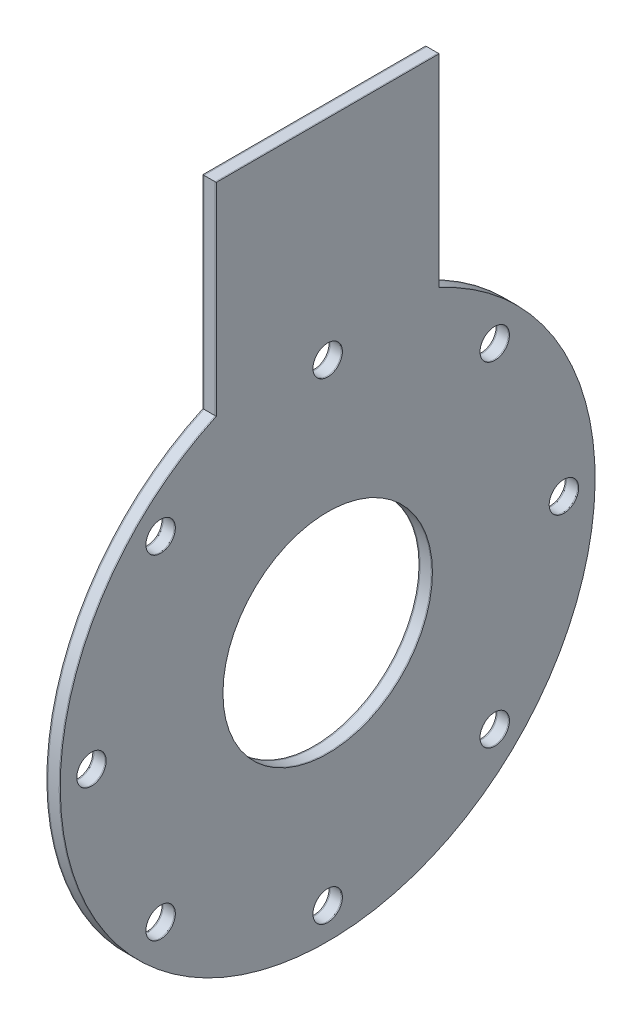
from build123d import *

# Parameters (mm, degrees)
SKETCH1_R                     = 60
SKETCH1_R_2                   = 23.5
BOSS_EXTRUDE1_DEPTH           = 0.25
SKETCH4_R                     = 23.5
BOSS_EXTRUDE4_DEPTH           = 2.5
SKETCH5_R                     = 23.5
BOSS_EXTRUDE5_DEPTH           = 0.25
SKETCH10_W                    = 3.3
SKETCH10_H                    = 3
M6_CLEARANCE_HOLE1_AT_2_COUNT = 2
M6_CLEARANCE_HOLE1_AT_2_PITCH = 40.564443831
M6_CLEARANCE_HOLE1_AT_3_COUNT = 2
M6_CLEARANCE_HOLE1_AT_3_PITCH = 74.953318806
M6_CLEARANCE_HOLE1_AT_4_COUNT = 2
M6_CLEARANCE_HOLE1_AT_4_PITCH = 97.931230446
M6_CLEARANCE_HOLE1_AT_5_COUNT = 2
M6_CLEARANCE_HOLE1_AT_5_PITCH = 106
M6_CLEARANCE_HOLE1_AT_6_COUNT = 2
M6_CLEARANCE_HOLE1_AT_6_PITCH = 97.931230446
M6_CLEARANCE_HOLE1_AT_7_COUNT = 2
M6_CLEARANCE_HOLE1_AT_7_PITCH = 74.953318806
M6_CLEARANCE_HOLE1_AT_8_COUNT = 2
M6_CLEARANCE_HOLE1_AT_8_PITCH = 40.564443831


with BuildPart() as part:
    # Sketch1 → Boss-Extrude1 (new body)
    with BuildSketch(Plane(origin=(0, 0, 0), x_dir=(0, 0, -1), z_dir=(1, 0, 0))):
        with BuildLine():
            Line((25, 100), (-25, 100))
            Line((-25, 100), (-25, 54.543560573))
            ThreePointArc((-25, 54.543560573), (0, 60), (25, 54.543560573))
            Line((25, 54.543560573), (25, 100))
        make_face()
        Circle(SKETCH1_R)
        Circle(SKETCH1_R_2, mode=Mode.SUBTRACT)
    extrude(amount=BOSS_EXTRUDE1_DEPTH)


with BuildPart() as body_2:
    # Sketch4 → Boss-Extrude4 (new body)
    with BuildSketch(Plane.ZY):
        with BuildLine():
            Line((25, 54.543560573), (25, 100))
            Line((25, 100), (-25, 100))
            Line((-25, 100), (-25, 54.543560573))
            ThreePointArc((-25, 54.543560573), (0, -60), (25, 54.543560573))
        make_face()
        Circle(SKETCH4_R, mode=Mode.SUBTRACT)
    extrude(amount=BOSS_EXTRUDE4_DEPTH)


with BuildPart() as body_3:
    # Sketch5 → Boss-Extrude5 (new body)
    with BuildSketch(Plane.ZY.offset(2.5)):
        with BuildLine():
            Line((25, 54.543560573), (25, 100))
            Line((25, 100), (-25, 100))
            Line((-25, 100), (-25, 54.543560573))
            ThreePointArc((-25, 54.543560573), (0, -60), (25, 54.543560573))
        make_face()
        Circle(SKETCH5_R, mode=Mode.SUBTRACT)
    extrude(amount=BOSS_EXTRUDE5_DEPTH)


with BuildPart() as m6_clearance_hole1_tool:
    # Sketch10 → M6 Clearance Hole1 (revolve)
    with BuildSketch(Plane(origin=(0.25, 37.476659403, -37.476659403), x_dir=(0, 0, -1), z_dir=(0, 1, 0))):
        with Locations((1.65, 1.5)):
            Rectangle(SKETCH10_W, SKETCH10_H)
    m6_clearance_hole1 = revolve(axis=Axis((6.6, 37.476659403, -37.476659403), (-1, 0, 0)))


with BuildPart() as part_1:
    add(part.part)

    # M6 Clearance Hole1: cut by m6_clearance_hole1_tool
    add(m6_clearance_hole1_tool.part, mode=Mode.SUBTRACT)


with BuildPart() as body_2_1:
    add(body_2.part)

    # M6 Clearance Hole1: cut by m6_clearance_hole1_tool
    add(m6_clearance_hole1_tool.part, mode=Mode.SUBTRACT)


with BuildPart() as body_3_1:
    add(body_3.part)

    # M6 Clearance Hole1: cut by m6_clearance_hole1_tool
    add(m6_clearance_hole1_tool.part, mode=Mode.SUBTRACT)


with BuildPart() as m6_clearance_hole1_at_2_tool:
    # M6 Clearance Hole1 at 2: M6 Clearance Hole1 ×2
    with Locations(*[Vector(0, -0.923879533, -0.382683432) * (i * M6_CLEARANCE_HOLE1_AT_2_PITCH) for i in range(1, M6_CLEARANCE_HOLE1_AT_2_COUNT)]):
        add(m6_clearance_hole1)


with BuildPart() as part_2:
    add(part_1.part)

    # M6 Clearance Hole1 at 2: cut by m6_clearance_hole1_at_2_tool
    add(m6_clearance_hole1_at_2_tool.part, mode=Mode.SUBTRACT)


with BuildPart() as body_2_2:
    add(body_2_1.part)

    # M6 Clearance Hole1 at 2: cut by m6_clearance_hole1_at_2_tool
    add(m6_clearance_hole1_at_2_tool.part, mode=Mode.SUBTRACT)


with BuildPart() as body_3_2:
    add(body_3_1.part)

    # M6 Clearance Hole1 at 2: cut by m6_clearance_hole1_at_2_tool
    add(m6_clearance_hole1_at_2_tool.part, mode=Mode.SUBTRACT)


with BuildPart() as m6_clearance_hole1_at_3_tool:
    # M6 Clearance Hole1 at 3: M6 Clearance Hole1 ×2
    with Locations(*[(0, -i * M6_CLEARANCE_HOLE1_AT_3_PITCH, 0) for i in range(1, M6_CLEARANCE_HOLE1_AT_3_COUNT)]):
        add(m6_clearance_hole1)


with BuildPart() as part_3:
    add(part_2.part)

    # M6 Clearance Hole1 at 3: cut by m6_clearance_hole1_at_3_tool
    add(m6_clearance_hole1_at_3_tool.part, mode=Mode.SUBTRACT)


with BuildPart() as body_2_3:
    add(body_2_2.part)

    # M6 Clearance Hole1 at 3: cut by m6_clearance_hole1_at_3_tool
    add(m6_clearance_hole1_at_3_tool.part, mode=Mode.SUBTRACT)


with BuildPart() as body_3_3:
    add(body_3_2.part)

    # M6 Clearance Hole1 at 3: cut by m6_clearance_hole1_at_3_tool
    add(m6_clearance_hole1_at_3_tool.part, mode=Mode.SUBTRACT)


with BuildPart() as m6_clearance_hole1_at_4_tool:
    # M6 Clearance Hole1 at 4: M6 Clearance Hole1 ×2
    with Locations(*[Vector(0, -0.923879533, 0.382683432) * (i * M6_CLEARANCE_HOLE1_AT_4_PITCH) for i in range(1, M6_CLEARANCE_HOLE1_AT_4_COUNT)]):
        add(m6_clearance_hole1)


with BuildPart() as part_4:
    add(part_3.part)

    # M6 Clearance Hole1 at 4: cut by m6_clearance_hole1_at_4_tool
    add(m6_clearance_hole1_at_4_tool.part, mode=Mode.SUBTRACT)


with BuildPart() as body_2_4:
    add(body_2_3.part)

    # M6 Clearance Hole1 at 4: cut by m6_clearance_hole1_at_4_tool
    add(m6_clearance_hole1_at_4_tool.part, mode=Mode.SUBTRACT)


with BuildPart() as body_3_4:
    add(body_3_3.part)

    # M6 Clearance Hole1 at 4: cut by m6_clearance_hole1_at_4_tool
    add(m6_clearance_hole1_at_4_tool.part, mode=Mode.SUBTRACT)


with BuildPart() as m6_clearance_hole1_at_5_tool:
    # M6 Clearance Hole1 at 5: M6 Clearance Hole1 ×2
    with Locations(*[Vector(0, -0.707106781, 0.707106781) * (i * M6_CLEARANCE_HOLE1_AT_5_PITCH) for i in range(1, M6_CLEARANCE_HOLE1_AT_5_COUNT)]):
        add(m6_clearance_hole1)


with BuildPart() as part_5:
    add(part_4.part)

    # M6 Clearance Hole1 at 5: cut by m6_clearance_hole1_at_5_tool
    add(m6_clearance_hole1_at_5_tool.part, mode=Mode.SUBTRACT)


with BuildPart() as body_2_5:
    add(body_2_4.part)

    # M6 Clearance Hole1 at 5: cut by m6_clearance_hole1_at_5_tool
    add(m6_clearance_hole1_at_5_tool.part, mode=Mode.SUBTRACT)


with BuildPart() as body_3_5:
    add(body_3_4.part)

    # M6 Clearance Hole1 at 5: cut by m6_clearance_hole1_at_5_tool
    add(m6_clearance_hole1_at_5_tool.part, mode=Mode.SUBTRACT)


with BuildPart() as m6_clearance_hole1_at_6_tool:
    # M6 Clearance Hole1 at 6: M6 Clearance Hole1 ×2
    with Locations(*[Vector(0, -0.382683432, 0.923879533) * (i * M6_CLEARANCE_HOLE1_AT_6_PITCH) for i in range(1, M6_CLEARANCE_HOLE1_AT_6_COUNT)]):
        add(m6_clearance_hole1)


with BuildPart() as part_6:
    add(part_5.part)

    # M6 Clearance Hole1 at 6: cut by m6_clearance_hole1_at_6_tool
    add(m6_clearance_hole1_at_6_tool.part, mode=Mode.SUBTRACT)


with BuildPart() as body_2_6:
    add(body_2_5.part)

    # M6 Clearance Hole1 at 6: cut by m6_clearance_hole1_at_6_tool
    add(m6_clearance_hole1_at_6_tool.part, mode=Mode.SUBTRACT)


with BuildPart() as body_3_6:
    add(body_3_5.part)

    # M6 Clearance Hole1 at 6: cut by m6_clearance_hole1_at_6_tool
    add(m6_clearance_hole1_at_6_tool.part, mode=Mode.SUBTRACT)


with BuildPart() as m6_clearance_hole1_at_7_tool:
    # M6 Clearance Hole1 at 7: M6 Clearance Hole1 ×2
    with Locations(*[(0, 0, i * M6_CLEARANCE_HOLE1_AT_7_PITCH) for i in range(1, M6_CLEARANCE_HOLE1_AT_7_COUNT)]):
        add(m6_clearance_hole1)


with BuildPart() as part_7:
    add(part_6.part)

    # M6 Clearance Hole1 at 7: cut by m6_clearance_hole1_at_7_tool
    add(m6_clearance_hole1_at_7_tool.part, mode=Mode.SUBTRACT)


with BuildPart() as body_2_7:
    add(body_2_6.part)

    # M6 Clearance Hole1 at 7: cut by m6_clearance_hole1_at_7_tool
    add(m6_clearance_hole1_at_7_tool.part, mode=Mode.SUBTRACT)


with BuildPart() as body_3_7:
    add(body_3_6.part)

    # M6 Clearance Hole1 at 7: cut by m6_clearance_hole1_at_7_tool
    add(m6_clearance_hole1_at_7_tool.part, mode=Mode.SUBTRACT)


with BuildPart() as m6_clearance_hole1_at_8_tool:
    # M6 Clearance Hole1 at 8: M6 Clearance Hole1 ×2
    with Locations(*[Vector(0, 0.382683432, 0.923879533) * (i * M6_CLEARANCE_HOLE1_AT_8_PITCH) for i in range(1, M6_CLEARANCE_HOLE1_AT_8_COUNT)]):
        add(m6_clearance_hole1)


with BuildPart() as part_8:
    add(part_7.part)

    # M6 Clearance Hole1 at 8: cut by m6_clearance_hole1_at_8_tool
    add(m6_clearance_hole1_at_8_tool.part, mode=Mode.SUBTRACT)


with BuildPart() as body_2_8:
    add(body_2_7.part)

    # M6 Clearance Hole1 at 8: cut by m6_clearance_hole1_at_8_tool
    add(m6_clearance_hole1_at_8_tool.part, mode=Mode.SUBTRACT)


with BuildPart() as body_3_8:
    add(body_3_7.part)

    # M6 Clearance Hole1 at 8: cut by m6_clearance_hole1_at_8_tool
    add(m6_clearance_hole1_at_8_tool.part, mode=Mode.SUBTRACT)


solid = Compound([part_8.part, body_2_8.part, body_3_8.part])
